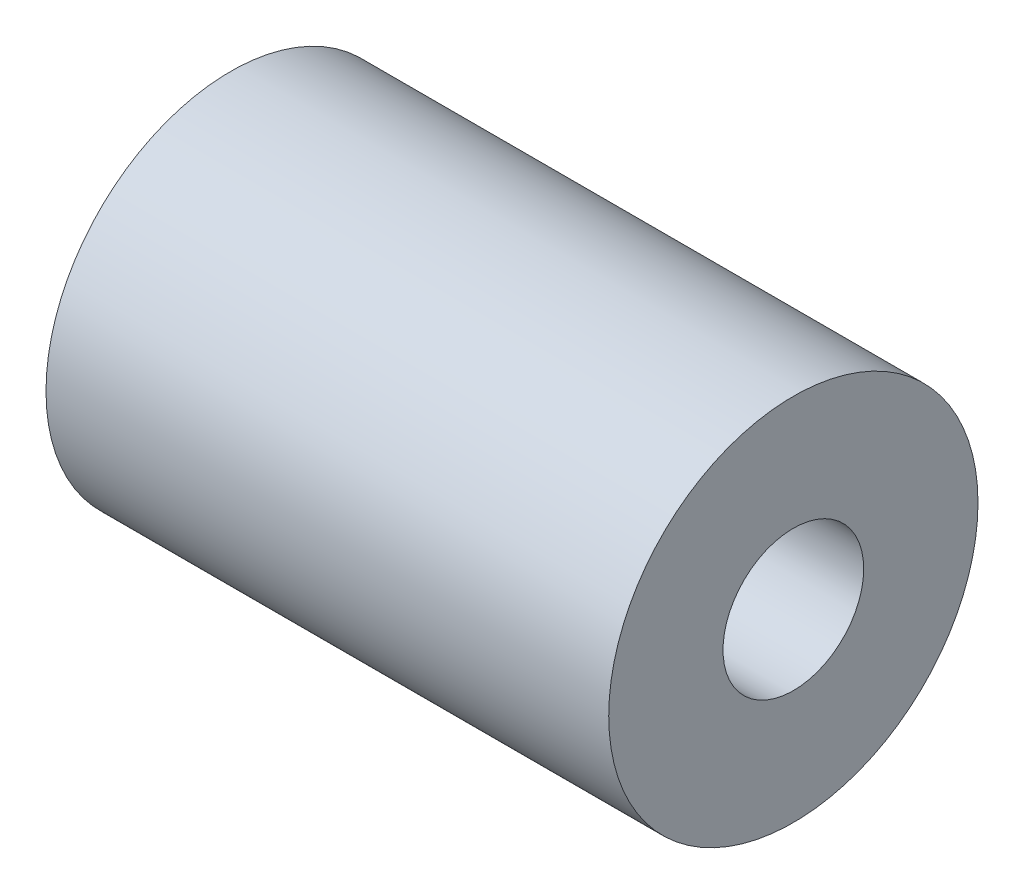
from build123d import *

# Parameters (mm, degrees)
SKETCH1_R          = 16.66875
EXTRUDE1_DEPTH     = 50.8
SKETCH2_R          = 6.35
CUT_EXTRUDE1_DEPTH = 25.4
SKETCH3_R          = 7.9375
CUT_EXTRUDE2_DEPTH = 25.4


with BuildPart() as part:
    # Sketch1 → Extrude1 (new body)
    with BuildSketch(Plane(origin=(0, 0, 0), x_dir=(0, 0, -1), z_dir=(1, 0, 0))):
        Circle(SKETCH1_R)
    extrude(amount=EXTRUDE1_DEPTH)

    # Sketch2 → Cut-Extrude1 (cut)
    with BuildSketch(Plane(origin=(50.8, 0, 0), x_dir=(0, 0, -1), z_dir=(1, 0, 0))):
        Circle(SKETCH2_R)
    extrude(amount=-CUT_EXTRUDE1_DEPTH, mode=Mode.SUBTRACT)

    # Sketch3 → Cut-Extrude2 (cut)
    with BuildSketch(Plane.ZY):
        Circle(SKETCH3_R)
    extrude(amount=-CUT_EXTRUDE2_DEPTH, mode=Mode.SUBTRACT)


solid = part.part
